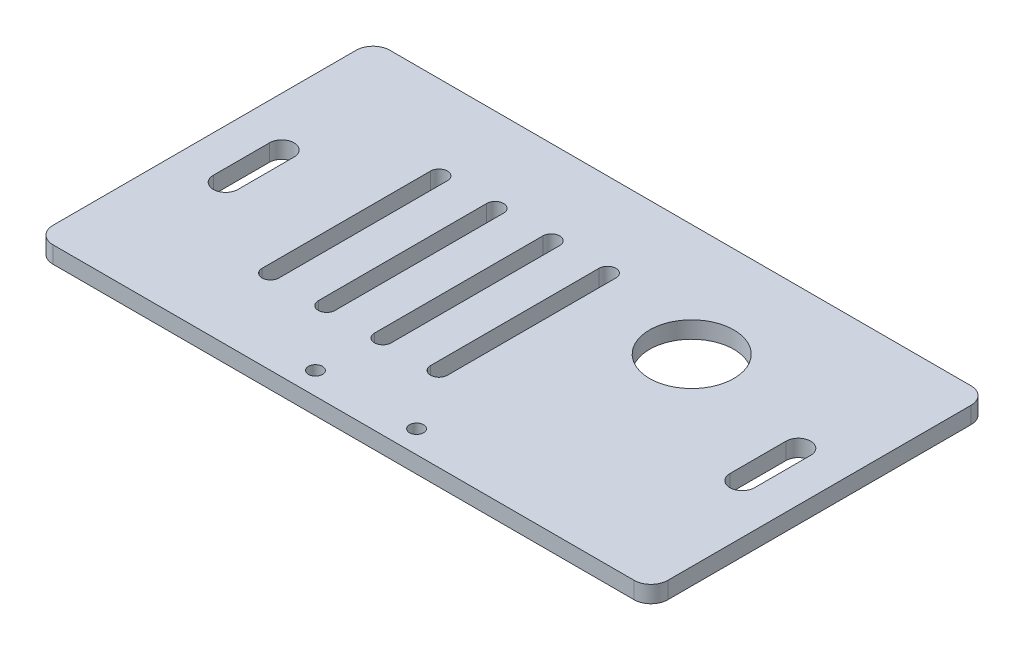
from build123d import *

# Parameters (mm, degrees)
SKETCH_1_W          = 109.5
SKETCH_1_H          = 60
EXTRUDE_1_DEPTH     = 3
SKETCH_2_R          = 1.25
CUT_EXTRUDE_1_DEPTH = 10
FILLET_1_R          = 3
CUT_EXTRUDE_2_DEPTH = 10
SKETCH_5_R          = 7.5
CUT_EXTRUDE_3_DEPTH = 10


with BuildPart() as part:
    # 草图1 → 凸台-拉伸1 (new body)
    with BuildSketch(Plane(origin=(0, 0, 0), x_dir=(1, 0, 0), z_dir=(0, 1, 0))):
        Rectangle(SKETCH_1_W, SKETCH_1_H)
    extrude(amount=EXTRUDE_1_DEPTH)

    # 草图2 → 切除-拉伸1 (cut)
    with BuildSketch(Plane(origin=(0, 3, 0), x_dir=(1, 0, 0), z_dir=(0, 1, 0))):
        with Locations((9, -26)):
            Circle(SKETCH_2_R)
        with Locations((-9, -26)):
            Circle(SKETCH_2_R)
    extrude(amount=-CUT_EXTRUDE_1_DEPTH, mode=Mode.SUBTRACT)

    # 圆角1
    fillet_1_edges = [part.edges().sort_by_distance(p)[0] for p in [
        (54.75, 1.5, 30),
        (-54.75, 1.5, 30),
        (-54.75, 1.5, -30),
        (54.75, 1.5, -30),
    ]]
    fillet(fillet_1_edges, radius=FILLET_1_R)

    # 草图3 → 切除-拉伸2 (cut)
    with BuildSketch(Plane(origin=(0, 3, 0), x_dir=(1, 0, 0), z_dir=(0, 1, 0))):
        with BuildLine():
            Line((-43.809910809, 5), (-43.809910809, -5))
            ThreePointArc((-43.809910809, -5), (-46, -7.190089191), (-48.190089191, -5))
            Line((-48.190089191, -5), (-48.190089191, 5))
            ThreePointArc((-48.190089191, 5), (-46, 7.190089191), (-43.809910809, 5))
        make_face()
        with BuildLine():
            Line((43.809910809, 5), (43.809910809, -5))
            ThreePointArc((43.809910809, -5), (46, -7.190089191), (48.190089191, -5))
            Line((48.190089191, -5), (48.190089191, 5))
            ThreePointArc((48.190089191, 5), (46, 7.190089191), (43.809910809, 5))
        make_face()
    extrude(amount=-CUT_EXTRUDE_2_DEPTH, mode=Mode.SUBTRACT)

    # 草图5 → 切除-拉伸3 (cut)
    with BuildSketch(Plane(origin=(0, 3, 0), x_dir=(1, 0, 0), z_dir=(0, 1, 0))):
        with Locations((22, 10)):
            Circle(SKETCH_5_R)
        with BuildLine():
            Line((-26.5, 15), (-26.5, -15))
            ThreePointArc((-26.5, -15), (-28, -16.5), (-29.5, -15))
            Line((-29.5, -15), (-29.5, 15))
            ThreePointArc((-29.5, 15), (-28, 16.5), (-26.5, 15))
        make_face()
        with BuildLine():
            Line((-16.5, 15), (-16.5, -15))
            ThreePointArc((-16.5, -15), (-18, -16.5), (-19.5, -15))
            Line((-19.5, -15), (-19.5, 15))
            ThreePointArc((-19.5, 15), (-18, 16.5), (-16.5, 15))
        make_face()
        with BuildLine():
            Line((-6.5, 15), (-6.5, -15))
            ThreePointArc((-6.5, -15), (-8, -16.5), (-9.5, -15))
            Line((-9.5, -15), (-9.5, 15))
            ThreePointArc((-9.5, 15), (-8, 16.5), (-6.5, 15))
        make_face()
        with BuildLine():
            Line((3.5, 15), (3.5, -15))
            ThreePointArc((3.5, -15), (2, -16.5), (0.5, -15))
            Line((0.5, -15), (0.5, 15))
            ThreePointArc((0.5, 15), (2, 16.5), (3.5, 15))
        make_face()
    extrude(amount=-CUT_EXTRUDE_3_DEPTH, mode=Mode.SUBTRACT)


solid = part.part
